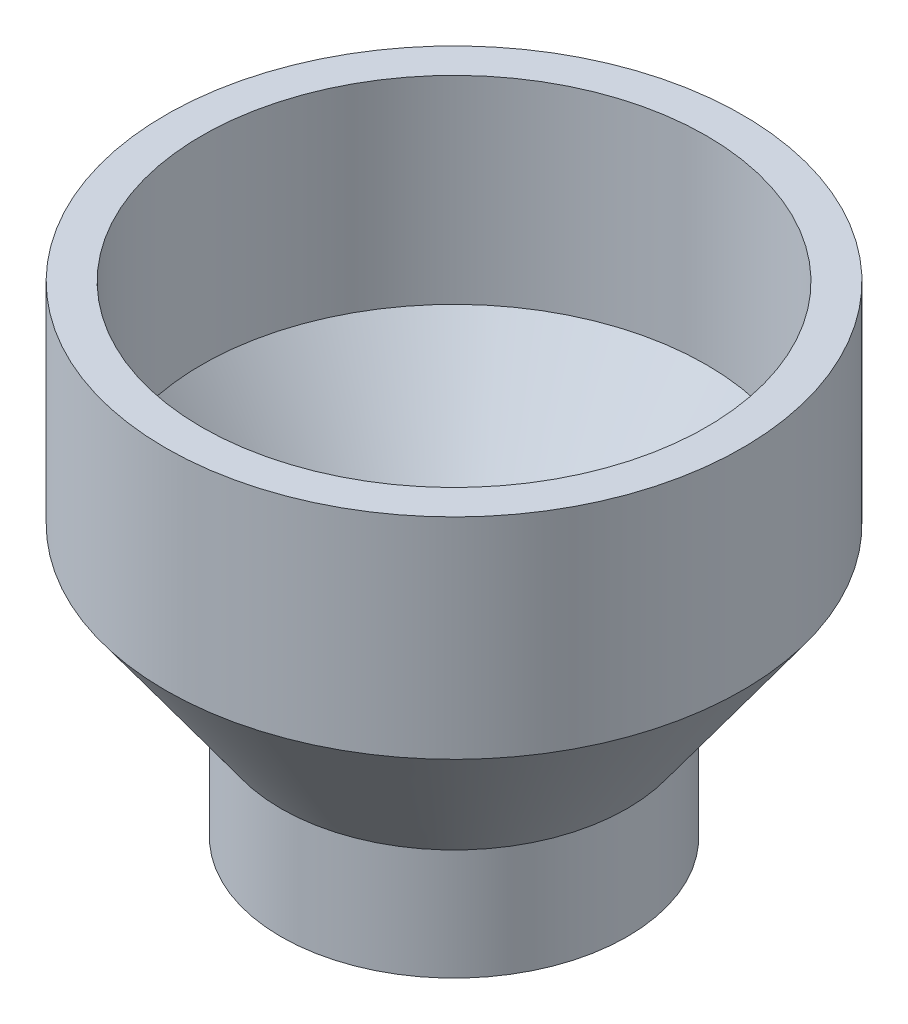
from build123d import *


with BuildPart() as part:
    # Sketch1 → Revolve-Thin1 (revolve)
    with BuildSketch(Plane.XY):
        Polygon((-24.13, 0), (-24.13, 21.59), (-44.45, 49.784), (-44.45, 84.709), (-50.8, 84.709), (-50.8, 47.734164011), (-30.48, 19.540164011), (-30.48, 0), align=None)
    revolve(axis=Axis((0, 0, 0), (0, -1, 0)))


solid = part.part
